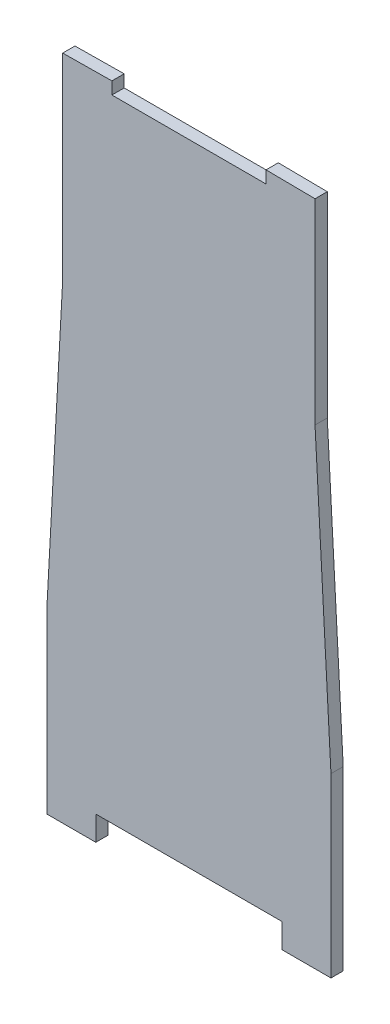
from build123d import *

# Parameters (mm, degrees)
BOSS_EXTRUDE1_DEPTH = 6.35


with BuildPart() as part:
    # Sketch1 → Boss-Extrude1 (new body)
    with BuildSketch(Plane.XY):
        Polygon((48.25455021, 47.376798163), (-48.25455021, 47.376798163), (-48.25455021, 34.676798163), (-73.66, 34.676798163), (-73.66, 50.26261194), (-73.66, 126.46261194), (-65.405, 278.86261194), (-65.405, 380.46261194), (-39.899935303, 380.734170325), (-39.899935303, 374.384170325), (40.006435928, 374.384170325), (40.006435928, 380.735602504), (65.405, 380.46261194), (65.405, 278.86261194), (73.66, 126.46261194), (73.66, 50.26261194), (73.66, 34.711944221), (48.25455021, 34.711944221), align=None)
    extrude(amount=BOSS_EXTRUDE1_DEPTH)


solid = part.part
